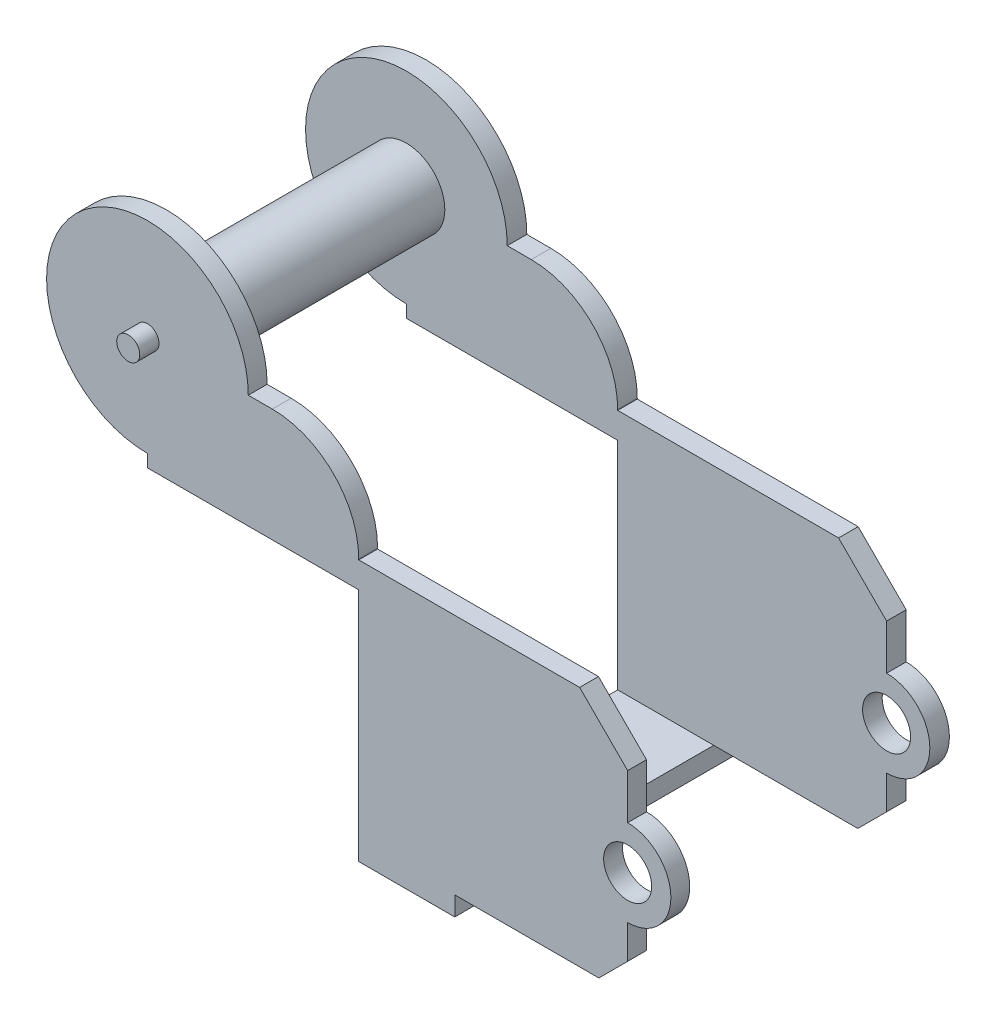
from build123d import *

# Parameters (mm, degrees)
SKETCH_1_R           = 4
SKETCH_1_R_2         = 2.50023196
EXTRUDE_3_DEPTH      = 29
SKETCH_5_W           = 29.813353088
SKETCH_5_H           = 25
CUT_EXTRUDE_2_DEPTH  = 50
SKETCH_6_W           = 25
SKETCH_6_H           = 54.055656888
CUT_EXTRUDE_3_DEPTH  = 50
SKETCH_7_R           = 4
SKETCH_7_R_2         = 1.2
EXTRUDE_4_DEPTH      = 29
SKETCH_10_R          = 1.2
EXTRUDE_5_DEPTH      = 2
EXTRUDE_5_DEPTH_BACK = 31


with BuildPart() as part:
    # 草图1 → 凸台-拉伸3 (new body)
    with BuildSketch(Plane.XY):
        with BuildLine():
            Line((-23.562506416, 27.500198397), (-23.562506416, 27.598880866))
            ThreePointArc((-23.562506416, 27.598880866), (-26.198545385, 33.962841897), (-32.562506416, 36.598880866))
            Line((-32.562506416, 36.598880866), (-35.062506416, 36.598880866))
            ThreePointArc((-35.062506416, 36.598880866), (-52.987127618, 44.023502068), (-45.562506416, 26.098880866))
            Line((-45.562506416, 26.098880866), (-45.562506416, 24.798880866))
            Line((-45.562506416, 24.798880866), (-23.562506416, 24.798880866))
            Line((-23.562506416, 24.798880866), (-23.562506416, 2.297860243))
            Line((-23.562506416, 2.297860243), (-23.562506416, 0.297860243))
            Line((-23.562506416, 0.297860243), (-13.562506416, 0.297860243))
            Line((-13.562506416, 0.297860243), (-13.562506416, 2.297860243))
            Line((-13.562506416, 2.297860243), (1.437493584, 2.297860243))
            Line((1.437493584, 2.297860243), (4.437493584, 5.297860243))
            Line((4.437493584, 5.297860243), (4.437493584, 8.798464088))
            ThreePointArc((4.437493584, 8.798464088), (8.937910362, 13.298880866), (4.437493584, 17.799297644))
            Line((4.437493584, 17.799297644), (4.437493584, 22.500198397))
            Line((4.437493584, 22.500198397), (-0.562506416, 27.500198397))
            Line((-0.562506416, 27.500198397), (-23.562506416, 27.500198397))
        make_face()
        with Locations((-45.562506416, 36.598880866)):
            Circle(SKETCH_1_R, mode=Mode.SUBTRACT)
        with Locations((4.437493584, 13.298880866)):
            Circle(SKETCH_1_R_2, mode=Mode.SUBTRACT)
    extrude(amount=EXTRUDE_3_DEPTH)

    # 草图5 → 切除-拉伸2 (cut)
    with BuildSketch(Plane.XZ.offset(-2.297860243)):
        with Locations((1.344170128, 14.537987409)):
            Rectangle(SKETCH_5_W, SKETCH_5_H)
    extrude(amount=-CUT_EXTRUDE_2_DEPTH, mode=Mode.SUBTRACT)

    # 草图6 → 切除-拉伸3 (cut)
    with BuildSketch(Plane(origin=(-13.562506416, 0, 0), x_dir=(0, 0, -1), z_dir=(1, 0, 0))):
        with Locations((-14.537987409, 29.325688687)):
            Rectangle(SKETCH_6_W, SKETCH_6_H)
    extrude(amount=-CUT_EXTRUDE_3_DEPTH, mode=Mode.SUBTRACT)

    # 草图7 → 凸台-拉伸4 (add)
    with BuildSketch(Plane.XY.offset(29)):
        with Locations((-45.562506416, 36.598880866)):
            Circle(SKETCH_7_R)
        with Locations((-45.562506416, 36.598880866)):
            Circle(SKETCH_7_R_2, mode=Mode.SUBTRACT)
    extrude(amount=-EXTRUDE_4_DEPTH)

    # 草图10 → 凸台-拉伸5 (add, two sides)
    with BuildSketch(Plane(origin=(0, 0, 0), x_dir=(-1, 0, 0), z_dir=(0, 0, -1))) as extrude_5_sk:
        with Locations((45.562506416, 36.598880866)):
            Circle(SKETCH_10_R)
    extrude(amount=EXTRUDE_5_DEPTH)
    extrude(extrude_5_sk.sketch, amount=-EXTRUDE_5_DEPTH_BACK)


solid = part.part
